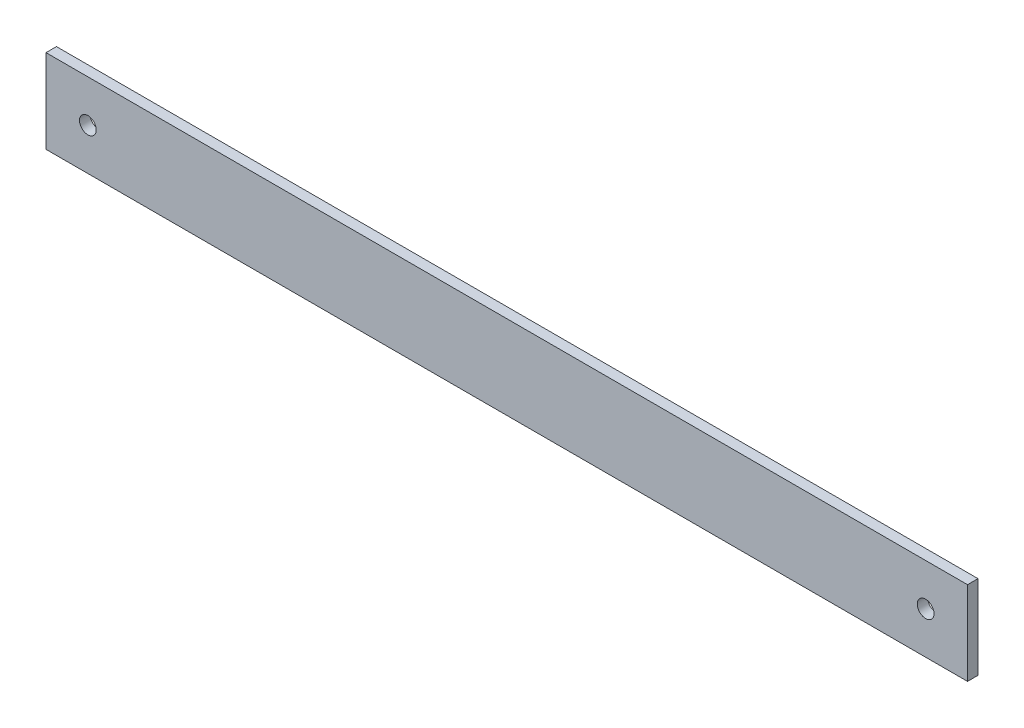
from build123d import *

# Parameters (mm, degrees)
SKETCH1_W           = 440
SKETCH1_H           = 40
SKETCH1_R           = 4
BOSS_EXTRUDE1_DEPTH = 5


with BuildPart() as part:
    # Sketch1 → Boss-Extrude1 (new body)
    with BuildSketch(Plane.XY):
        Rectangle(SKETCH1_W, SKETCH1_H)
        with Locations((200, 0)):
            Circle(SKETCH1_R, mode=Mode.SUBTRACT)
        with Locations((-200, 0)):
            Circle(SKETCH1_R, mode=Mode.SUBTRACT)
    extrude(amount=BOSS_EXTRUDE1_DEPTH)


solid = part.part
